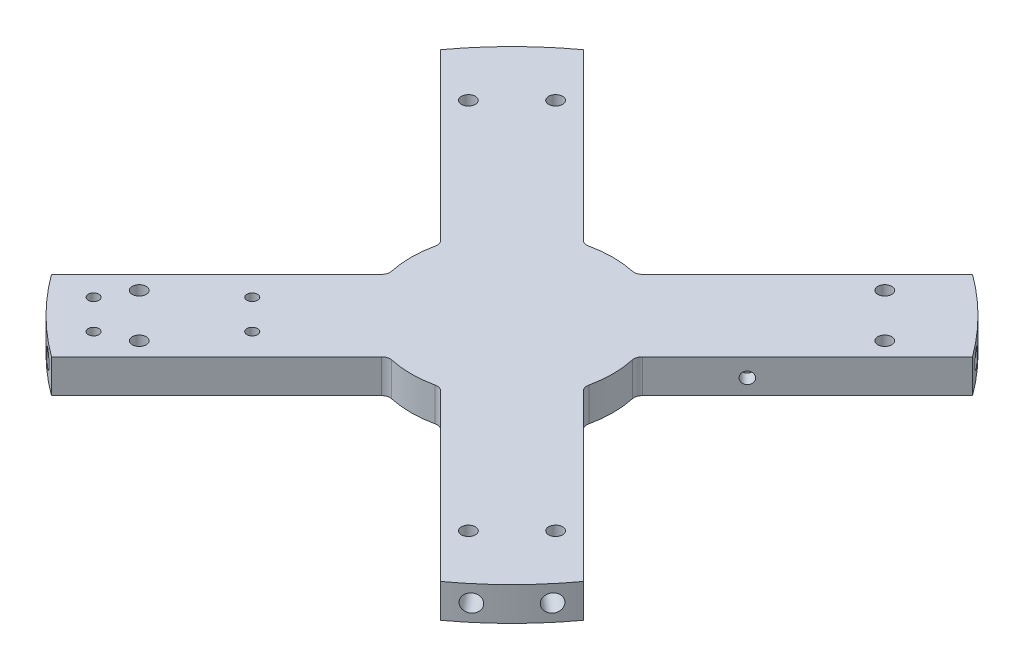
from build123d import *

# Parameters (mm, degrees)
BOSS_EXTRUDE3_DEPTH = 15.24
SKETCH6_R           = 3.175
CUT_EXTRUDE2_DEPTH  = 16.24
CUT_EXTRUDE6_REACH  = 17.24
SKETCH53_R          = 2.413
FILLET1_R           = 3.81
SKETCH57_R          = 3.96875
CUT_EXTRUDE8_DEPTH  = 11.43
SKETCH55_R          = 3.96875
CUT_EXTRUDE9_DEPTH  = 11.43
CIRPATTERN2_COUNT   = 4
SKETCH59_R          = 2.605475785
CUT_EXTRUDE11_DEPTH = 6.35
SKETCH60_R          = 2.660599197
CUT_EXTRUDE12_DEPTH = 6.35
SKETCH62_R          = 2.54
CUT_EXTRUDE14_DEPTH = 3.81


with BuildPart() as part:
    # Sketch5 → Boss-Extrude3 (new body)
    with BuildSketch(Plane(origin=(0, 0, 0), x_dir=(1, 0, 0), z_dir=(0, 1, 0))):
        with BuildLine():
            Line((-11.833206742, -44.162128778), (-88.108068982, -120.436991017))
            ThreePointArc((-88.108068982, -120.436991017), (-105.518009423, -105.518009423), (-120.436991017, -88.108068982))
            Line((-120.436991017, -88.108068982), (-44.162128778, -11.833206742))
            ThreePointArc((-44.162128778, -11.833206742), (-45.72, 0), (-44.162128778, 11.833206742))
            Line((-44.162128778, 11.833206742), (-120.436991017, 88.108068982))
            ThreePointArc((-120.436991017, 88.108068982), (-105.518009423, 105.518009423), (-88.108068982, 120.436991017))
            Line((-88.108068982, 120.436991017), (-11.833206742, 44.162128778))
            ThreePointArc((-11.833206742, 44.162128778), (0, 45.72), (11.833206742, 44.162128778))
            Line((11.833206742, 44.162128778), (88.108068982, 120.436991017))
            ThreePointArc((88.108068982, 120.436991017), (105.518009423, 105.518009423), (120.436991017, 88.108068982))
            Line((120.436991017, 88.108068982), (44.162128778, 11.833206742))
            ThreePointArc((44.162128778, 11.833206742), (45.72, 0), (44.162128778, -11.833206742))
            Line((44.162128778, -11.833206742), (120.436991017, -88.108068982))
            ThreePointArc((120.436991017, -88.108068982), (105.518009423, -105.518009423), (88.108068982, -120.436991017))
            Line((88.108068982, -120.436991017), (11.833206742, -44.162128778))
            ThreePointArc((11.833206742, -44.162128778), (0, -45.72), (-11.833206742, -44.162128778))
        make_face()
    extrude(amount=BOSS_EXTRUDE3_DEPTH)

    # Sketch6 → Cut-Extrude2 (cut, through all)
    with BuildSketch(Plane(origin=(0, 15.24, 0), x_dir=(1, 0, 0), z_dir=(0, 1, 0))):
        with Locations((-74.536125805, -94.292689271)):
            Circle(SKETCH6_R)
        with Locations((-94.292689271, -74.536125805)):
            Circle(SKETCH6_R)
        with Locations((94.292689271, -74.536125805)):
            Circle(SKETCH6_R)
        with Locations((74.536125805, -94.292689271)):
            Circle(SKETCH6_R)
        with Locations((94.292689271, 74.536125805)):
            Circle(SKETCH6_R)
        with Locations((74.536125805, 94.292689271)):
            Circle(SKETCH6_R)
        with Locations((-94.292689271, 74.536125805)):
            Circle(SKETCH6_R)
        with Locations((-74.536125805, 94.292689271)):
            Circle(SKETCH6_R)
    extrude(amount=-CUT_EXTRUDE2_DEPTH, mode=Mode.SUBTRACT)

    # Sketch53 → Cut-Extrude6 (cut, up to next)
    with BuildSketch(Plane(origin=(0, 15.24, 0), x_dir=(1, 0, 0), z_dir=(0, 1, 0)), mode=Mode.PRIVATE) as cut_extrude6_sk1:
        with Locations((-88.455522793, -101.027881362)):
            Circle(SKETCH53_R)
    cut_extrude6_tool1 = extrude(cut_extrude6_sk1.sketch, amount=-CUT_EXTRUDE6_REACH, mode=Mode.PRIVATE) & part.part
    add(cut_extrude6_tool1.solids().sort_by_distance((-88.455523, 15.24, 101.027881))[0], mode=Mode.SUBTRACT)
    # Sketch53 → Cut-Extrude6 (cut, up to next)
    with BuildSketch(Plane(origin=(0, 15.24, 0), x_dir=(1, 0, 0), z_dir=(0, 1, 0)), mode=Mode.PRIVATE) as cut_extrude6_sk2:
        with Locations((-52.534498308, -65.106856878)):
            Circle(SKETCH53_R)
    cut_extrude6_tool2 = extrude(cut_extrude6_sk2.sketch, amount=-CUT_EXTRUDE6_REACH, mode=Mode.PRIVATE) & part.part
    add(cut_extrude6_tool2.solids().sort_by_distance((-52.534498, 15.24, 65.106857))[0], mode=Mode.SUBTRACT)
    # Sketch53 → Cut-Extrude6 (cut, up to next)
    with BuildSketch(Plane(origin=(0, 15.24, 0), x_dir=(1, 0, 0), z_dir=(0, 1, 0)), mode=Mode.PRIVATE) as cut_extrude6_sk3:
        with Locations((-101.925906974, -87.55749718)):
            Circle(SKETCH53_R)
    cut_extrude6_tool3 = extrude(cut_extrude6_sk3.sketch, amount=-CUT_EXTRUDE6_REACH, mode=Mode.PRIVATE) & part.part
    add(cut_extrude6_tool3.solids().sort_by_distance((-101.925907, 15.24, 87.557497))[0], mode=Mode.SUBTRACT)
    # Sketch53 → Cut-Extrude6 (cut, up to next)
    with BuildSketch(Plane(origin=(0, 15.24, 0), x_dir=(1, 0, 0), z_dir=(0, 1, 0)), mode=Mode.PRIVATE) as cut_extrude6_sk4:
        with Locations((-66.00488249, -51.636472696)):
            Circle(SKETCH53_R)
    cut_extrude6_tool4 = extrude(cut_extrude6_sk4.sketch, amount=-CUT_EXTRUDE6_REACH, mode=Mode.PRIVATE) & part.part
    add(cut_extrude6_tool4.solids().sort_by_distance((-66.004882, 15.24, 51.636473))[0], mode=Mode.SUBTRACT)

    # Fillet1
    fillet1_edges = [part.edges().sort_by_distance(p)[0] for p in [
        (-44.162128778, 7.62, 11.833206742),
        (-44.162128778, 7.62, -11.833206742),
        (-11.833206742, 7.62, -44.162128778),
        (11.833206742, 7.62, -44.162128778),
        (44.162128778, 7.62, -11.833206742),
        (44.162128778, 7.62, 11.833206742),
        (11.833206742, 7.62, 44.162128778),
        (-11.833206742, 7.62, 44.162128778),
    ]]
    fillet(fillet1_edges, radius=FILLET1_R)

    # Sketch57 → Cut-Extrude8 (cut)
    with BuildSketch(Plane(origin=(-114.312982024, 0, 95.919981055), x_dir=(0.64278761, 0, 0.766044443), z_dir=(-0.766044443, 0, 0.64278761))):
        with Locations((0, 7.62)):
            Circle(SKETCH57_R)
    cut_extrude8 = extrude(amount=-CUT_EXTRUDE8_DEPTH, mode=Mode.SUBTRACT)

    # Sketch55 → Cut-Extrude9 (cut)
    with BuildSketch(Plane(origin=(-95.919981055, 0, 114.312982024), x_dir=(0.766044443, 0, 0.64278761), z_dir=(-0.64278761, 0, 0.766044443))):
        with Locations((0, 7.62)):
            Circle(SKETCH55_R)
    cut_extrude9 = extrude(amount=-CUT_EXTRUDE9_DEPTH, mode=Mode.SUBTRACT)

    # CirPattern2: Cut-Extrude8, Cut-Extrude9 ×4 about axis
    cirpattern2_axis = Axis((0, 0, 0), (0, 1, 0))
    for i in range(1, CIRPATTERN2_COUNT):
        add(cut_extrude8.rotate(cirpattern2_axis, i * 360 / CIRPATTERN2_COUNT), mode=Mode.SUBTRACT)
        add(cut_extrude9.rotate(cirpattern2_axis, i * 360 / CIRPATTERN2_COUNT), mode=Mode.SUBTRACT)

    # Sketch59 → Cut-Extrude11 (cut)
    with BuildSketch(Plane(origin=(-16.164461018, 0, -16.164461018), x_dir=(-0.707106781, 0, 0.707106781), z_dir=(-0.707106781, 0, -0.707106781))):
        with Locations((-75.363184789, 6.985)):
            Circle(SKETCH59_R)
    extrude(amount=-CUT_EXTRUDE11_DEPTH, mode=Mode.SUBTRACT)

    # Sketch60 → Cut-Extrude12 (cut)
    with BuildSketch(Plane(origin=(16.164461018, 0, 16.164461018), x_dir=(0.707106781, 0, -0.707106781), z_dir=(0.707106781, 0, 0.707106781))):
        with Locations((75.363184789, 6.985)):
            Circle(SKETCH60_R)
    extrude(amount=-CUT_EXTRUDE12_DEPTH, mode=Mode.SUBTRACT)

    # Sketch62 → Cut-Extrude14 (cut)
    with BuildSketch(Plane.XZ):
        with Locations((93.894945093, -94.405023641)):
            Circle(SKETCH62_R)
    extrude(amount=-CUT_EXTRUDE14_DEPTH, mode=Mode.SUBTRACT)


solid = part.part
